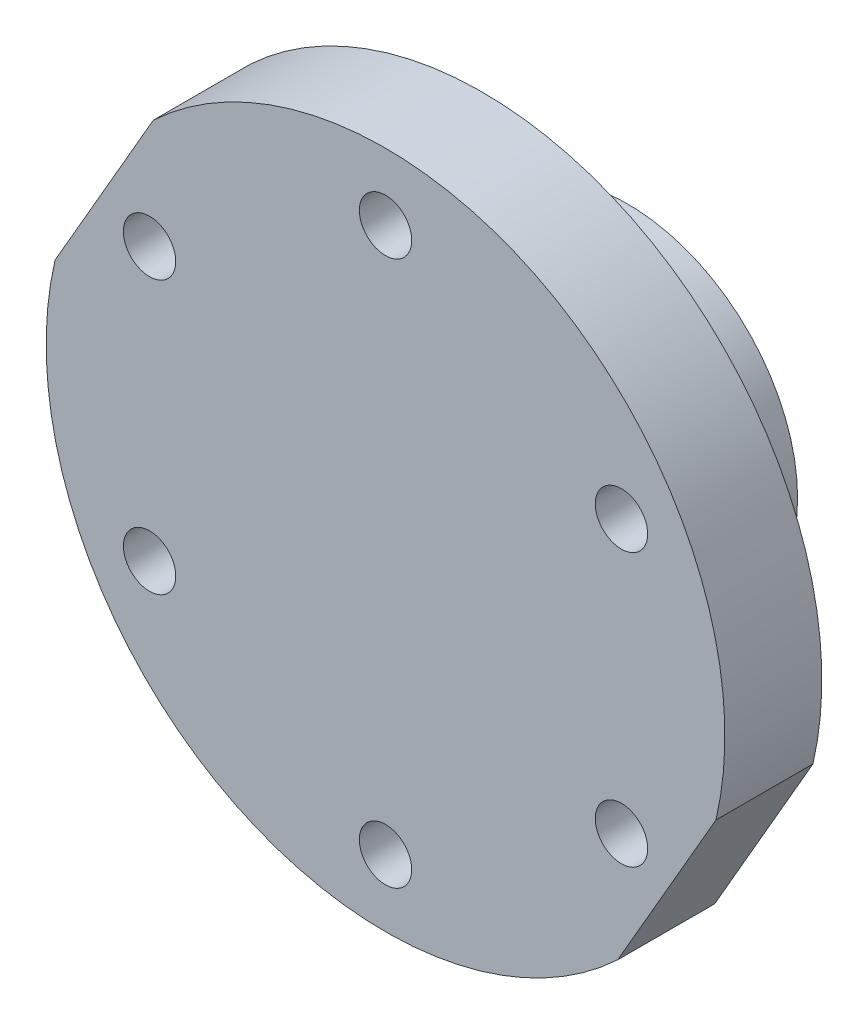
from build123d import *

# Parameters (mm, degrees)
SKETCH3_R               = 35
SKETCH3_R_2             = 6.15
BOSS_EXTRUDE1_DEPTH     = 10
SKETCH4_R               = 17.5
SKETCH4_R_2             = 6.15
BOSS_EXTRUDE2_DEPTH     = 15
SKETCH5_R               = 6.15
BOSS_EXTRUDE3_DEPTH     = 3
SKETCH7_R               = 2.7
CUT_EXTRUDE1_DEPTH      = 6
CUT_EXTRUDE2_DEPTH      = 10
SKETCH9_R               = 1.65
CUT_EXTRUDE3_DEPTH      = 84.669466186
CUT_EXTRUDE3_DEPTH_BACK = 84.669466186
CUT_EXTRUDE4_DEPTH      = 8.75
CUT_EXTRUDE5_START      = 20
SKETCH11_R              = 2.8
CUT_EXTRUDE5_DEPTH      = 5
SKETCH17_R              = 2.1
CUT_EXTRUDE6_DEPTH      = 3.5
CUT_EXTRUDE7_DEPTH      = 4


with BuildPart() as part:
    # Sketch3 → Boss-Extrude1 (new body)
    with BuildSketch(Plane.XY):
        Circle(SKETCH3_R)
        Circle(SKETCH3_R_2, mode=Mode.SUBTRACT)
    extrude(amount=-BOSS_EXTRUDE1_DEPTH)

    # Sketch4 → Boss-Extrude2 (add)
    with BuildSketch(Plane(origin=(0, 0, -10), x_dir=(-1, 0, 0), z_dir=(0, 0, -1))):
        with Locations(Location((0, 0, 0), (0, 0, 180))):
            Circle(SKETCH4_R)
        with Locations(Location((0, 0, 0), (0, 0, 180))):
            Circle(SKETCH4_R_2, mode=Mode.SUBTRACT)
    extrude(amount=BOSS_EXTRUDE2_DEPTH)

    # Sketch5 → Boss-Extrude3 (add)
    with BuildSketch(Plane.XY):
        Circle(SKETCH5_R)
    extrude(amount=-BOSS_EXTRUDE3_DEPTH)

    # Sketch7 → Cut-Extrude1 (cut)
    with BuildSketch(Plane.XY):
        with Locations((-24.335313846, 14.05)):
            Circle(SKETCH7_R)
        with Locations((-24.335313846, -14.05)):
            Circle(SKETCH7_R)
        with Locations((0, -28.1)):
            Circle(SKETCH7_R)
        with Locations((24.335313846, -14.05)):
            Circle(SKETCH7_R)
        with Locations((24.335313846, 14.05)):
            Circle(SKETCH7_R)
        with Locations((0, 28.1)):
            Circle(SKETCH7_R)
    extrude(amount=-CUT_EXTRUDE1_DEPTH, mode=Mode.SUBTRACT)

    # Sketch8 → Cut-Extrude2 (cut)
    with BuildSketch(Plane.XY):
        with BuildLine():
            Line((-23.943567294, 25.528524933), (-34.08013476, 7.971475067))
            ThreePointArc((-34.08013476, 7.971475067), (-30.310889132, 17.5), (-23.943567294, 25.528524933))
        make_face()
        with BuildLine():
            Line((34.08013476, -7.971475067), (23.943567294, -25.528524933))
            ThreePointArc((23.943567294, -25.528524933), (30.310889132, -17.5), (34.08013476, -7.971475067))
        make_face()
    extrude(amount=-CUT_EXTRUDE2_DEPTH, mode=Mode.SUBTRACT)

    # Sketch9 → Cut-Extrude3 (cut, two sides)
    with BuildSketch(Plane(origin=(-29.011851027, 16.75, -10), x_dir=(0.8660254037844387, -0.4999999999999999, 0), z_dir=(0.49999999999999994, 0.8660254037844388, 0))) as cut_extrude3_sk:
        with Locations(Location((33.5, 7.5, 0), (0, 0, 180))):
            Circle(SKETCH9_R)
    extrude(amount=CUT_EXTRUDE3_DEPTH, mode=Mode.SUBTRACT)
    extrude(cut_extrude3_sk.sketch, amount=-CUT_EXTRUDE3_DEPTH_BACK, mode=Mode.SUBTRACT)

    # Sketch10 → Cut-Extrude4 (cut, symmetric)
    with BuildSketch(Plane(origin=(-29.011851027, 16.75, -10), x_dir=(0.8660254037844387, -0.4999999999999999, 0), z_dir=(0.49999999999999994, 0.8660254037844388, 0))):
        Polygon((35.174315781, 10.4), (31.825684219, 10.4), (30.151368439, 7.5), (31.825684219, 4.6), (35.174315781, 4.6), (36.848631561, 7.5), align=None)
    extrude(amount=CUT_EXTRUDE4_DEPTH, both=True, mode=Mode.SUBTRACT)

    # Sketch11 → Cut-Extrude5 (cut)
    with BuildSketch(Plane(origin=(-29.011851027, 16.75, -10), x_dir=(0.8660254037844387, -0.4999999999999999, 0), z_dir=(0.49999999999999994, 0.8660254037844388, 0)).offset(CUT_EXTRUDE5_START)):
        with Locations(Location((33.5, 7.5, 0), (0, 0, 180))):
            Circle(SKETCH11_R)
    cut_extrude5 = extrude(amount=-CUT_EXTRUDE5_DEPTH, mode=Mode.SUBTRACT)

    # Mirror1: Cut-Extrude5 across plane
    add(cut_extrude5.mirror(Plane(origin=(-29.011851027, 16.75, -10), x_dir=(0, 0, 1), z_dir=(0.49999999999999994, 0.8660254037844388, 0))), mode=Mode.SUBTRACT)

    # Sketch17 → Cut-Extrude6 (cut)
    with BuildSketch(Plane(origin=(0, 0, -10), x_dir=(-1, 0, 0), z_dir=(0, 0, -1))):
        with Locations((14.05, 24.335313846)):
            Circle(SKETCH17_R)
        with Locations((28.1, 0)):
            Circle(SKETCH17_R)
        with Locations(Location((-28.1, 0, 0), (0, 0, 180))):
            Circle(SKETCH17_R)
        with Locations(Location((-14.05, -24.335313846, 0), (0, 0, 180))):
            Circle(SKETCH17_R)
    extrude(amount=-CUT_EXTRUDE6_DEPTH, mode=Mode.SUBTRACT)

    # Sketch18 → Cut-Extrude7 (cut)
    with BuildSketch(Plane(origin=(0, 0, -10), x_dir=(-1, 0, 0), z_dir=(0, 0, -1))):
        Polygon((26.644714923, 18.05), (22.02591277, 18.05), (19.716511693, 14.05), (22.02591277, 10.05), (26.644714923, 10.05), (28.954116, 14.05), align=None)
        Polygon((-2.309401077, 32.1), (-4.618802154, 28.1), (-2.309401077, 24.1), (2.309401077, 24.1), (4.618802154, 28.1), (2.309401077, 32.1), align=None)
        Polygon((28.954116, -14.05), (26.644714923, -10.05), (22.02591277, -10.05), (19.716511693, -14.05), (22.02591277, -18.05), (26.644714923, -18.05), align=None)
        Polygon((2.309401077, -32.1), (4.618802154, -28.1), (2.309401077, -24.1), (-2.309401077, -24.1), (-4.618802154, -28.1), (-2.309401077, -32.1), align=None)
        Polygon((-26.644714923, -18.05), (-22.02591277, -18.05), (-19.716511693, -14.05), (-22.02591277, -10.05), (-26.644714923, -10.05), (-28.954116, -14.05), align=None)
        Polygon((-28.954116, 14.05), (-26.644714923, 10.05), (-22.02591277, 10.05), (-19.716511693, 14.05), (-22.02591277, 18.05), (-26.644714923, 18.05), align=None)
    extrude(amount=-CUT_EXTRUDE7_DEPTH, mode=Mode.SUBTRACT)


solid = part.part
